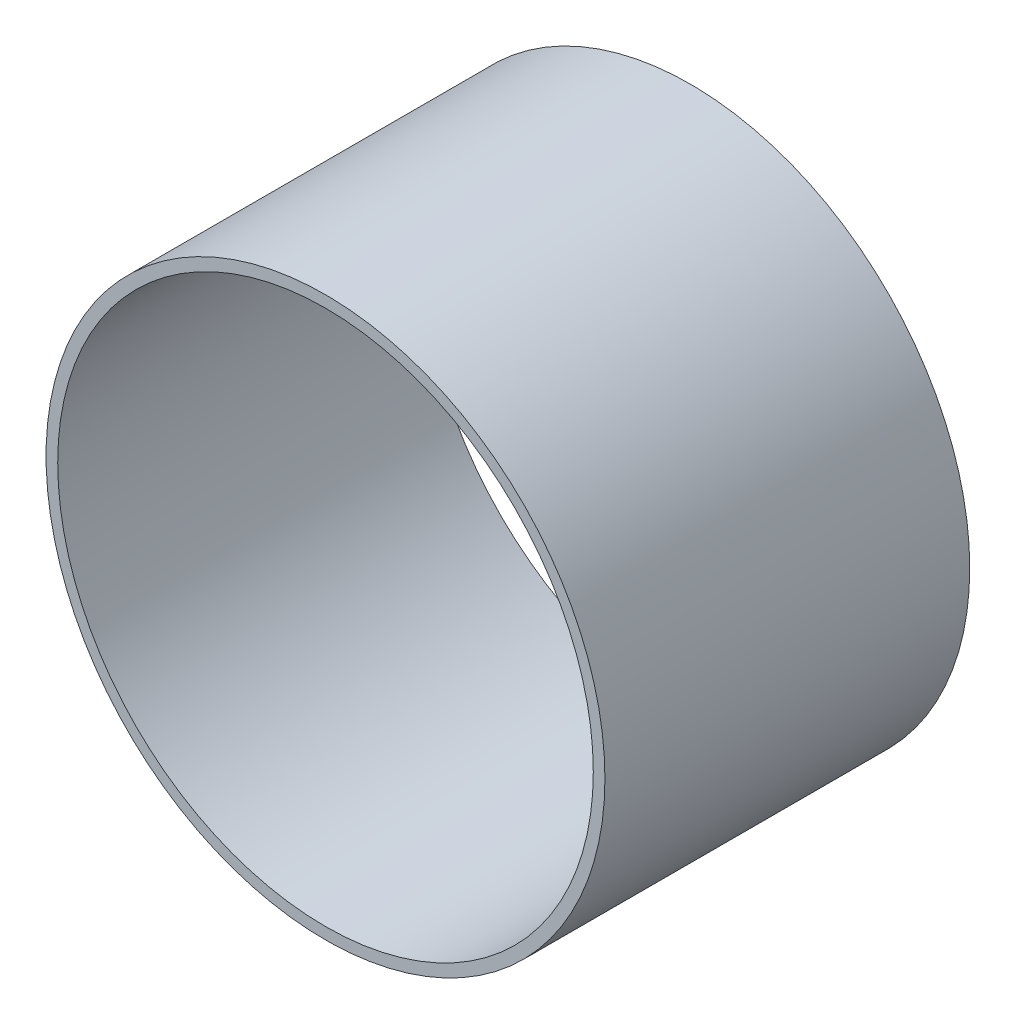
from build123d import *

# Parameters (mm, degrees)
SKETCH1_R           = 114.3
SKETCH1_R_2         = 109.5375
BOSS_EXTRUDE1_DEPTH = 74.6125


with BuildPart() as part:
    # Sketch1 → Boss-Extrude1 (new body, symmetric)
    with BuildSketch(Plane.XY):
        Circle(SKETCH1_R)
        Circle(SKETCH1_R_2, mode=Mode.SUBTRACT)
    extrude(amount=BOSS_EXTRUDE1_DEPTH, both=True)


solid = part.part
